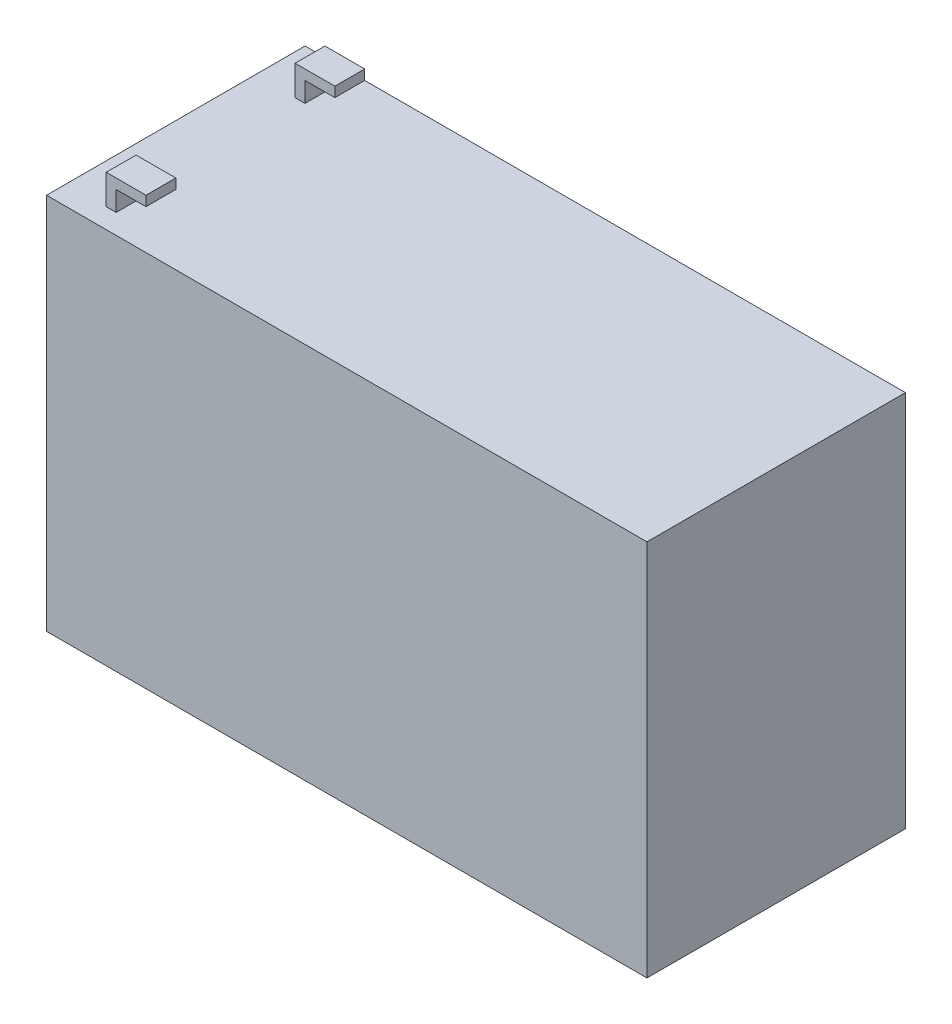
from build123d import *

# Parameters (mm, degrees)
SKETCH1_W           = 151
SKETCH1_H           = 95
BOSS_EXTRUDE1_DEPTH = 65
BOSS_EXTRUDE2_DEPTH = 65
CUT_EXTRUDE1_REACH  = 143
SKETCH3_W           = 5
SKETCH3_H           = 7.5
SKETCH3_W_2         = 40
SHELL1_T            = -1


with BuildPart() as part:
    # Sketch1 → Boss-Extrude1 (new body)
    with BuildSketch(Plane.XY):
        Rectangle(SKETCH1_W, SKETCH1_H)
    extrude(amount=-BOSS_EXTRUDE1_DEPTH)

    # Sketch2 → Boss-Extrude2 (add)
    with BuildSketch(Plane.XY):
        Polygon((-65.5, 47.5), (-65.5, 55), (-55.5, 55), (-55.5, 52.5), (-63, 52.5), (-63, 47.5), align=None)
    extrude(amount=-BOSS_EXTRUDE2_DEPTH)

    # Sketch3 → Cut-Extrude1 (cut, up to next)
    with BuildSketch(Plane.ZY.offset(65.5), mode=Mode.PRIVATE) as cut_extrude1_sk1:
        with Locations((-62.5, 51.25)):
            Rectangle(SKETCH3_W, SKETCH3_H)
    cut_extrude1_tool1 = extrude(cut_extrude1_sk1.sketch, amount=-CUT_EXTRUDE1_REACH, mode=Mode.PRIVATE) & part.part
    add(cut_extrude1_tool1.solids().sort_by_distance((-65.5, 51.25, -62.5))[0], mode=Mode.SUBTRACT)
    # Sketch3 → Cut-Extrude1 (cut, up to next)
    with BuildSketch(Plane.ZY.offset(65.5), mode=Mode.PRIVATE) as cut_extrude1_sk2:
        with Locations((-32.5, 51.25)):
            Rectangle(SKETCH3_W_2, SKETCH3_H)
    cut_extrude1_tool2 = extrude(cut_extrude1_sk2.sketch, amount=-CUT_EXTRUDE1_REACH, mode=Mode.PRIVATE) & part.part
    add(cut_extrude1_tool2.solids().sort_by_distance((-65.5, 51.25, -32.5))[0], mode=Mode.SUBTRACT)
    # Sketch3 → Cut-Extrude1 (cut, up to next)
    with BuildSketch(Plane.ZY.offset(65.5), mode=Mode.PRIVATE) as cut_extrude1_sk3:
        with Locations((-2.5, 51.25)):
            Rectangle(SKETCH3_W, SKETCH3_H)
    cut_extrude1_tool3 = extrude(cut_extrude1_sk3.sketch, amount=-CUT_EXTRUDE1_REACH, mode=Mode.PRIVATE) & part.part
    add(cut_extrude1_tool3.solids().sort_by_distance((-65.5, 51.25, -2.5))[0], mode=Mode.SUBTRACT)

    # Shell1
    shell1_openings = [part.faces().sort_by_distance(p)[0] for p in [
        (0, -47.5, -32.5),
    ]]
    offset(amount=SHELL1_T, openings=shell1_openings, kind=Kind.INTERSECTION)


solid = part.part
